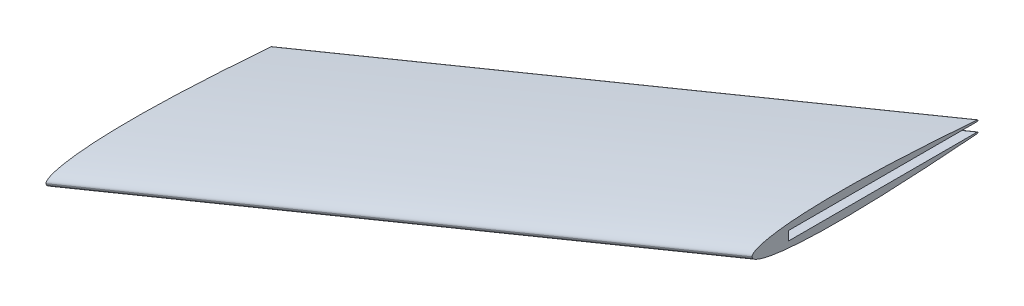
from build123d import *

# Parameters (mm, degrees)
SHAPE_OF_FINS_W                        = 146.05
SHAPE_OF_FINS_H                        = 76.2
CUT_FIN_SHAPE_BOTTOM_NO_MIDPLANE_DEPTH = 1.5875
SHAPE_OF_FINS_2_W                      = 146.05
SHAPE_OF_FINS_2_H                      = 76.2
CUT_FIN_SHAPE_TOP_NO_MIDPLANE_DEPTH    = 1.5875
FILLET1_R                              = 0.254


with BuildPart() as part:
    # Sketch2 → Loft1 section 0
    with BuildSketch(Plane(origin=(0, 0, 0), x_dir=(0, 0, -1), z_dir=(1, 0, 0))):
        with BuildLine():
            add(Edge.make_bspline(
                [(0, 0), (6.037e-05, 0.063965482), (0.008337384, 0.147065594), (0.033006292, 0.251891655), (0.08645397, 0.385600932), (0.14207511, 0.49175055), (0.2260735, 0.616551323), (0.352403438, 0.764641209), (0.538628729, 0.939487069), (0.828348412, 1.156294496), (1.308084735, 1.439447596), (2.168542592, 1.828433537), (3.779864919, 2.360255288), (6.811797919, 3.043241983), (11.632647218, 3.715252615), (18.029726602, 4.209542087), (25.596479128, 4.457376446), (33.615045989, 4.467520125), (41.631691137, 4.296624051), (48.642181709, 4.028955027), (54.648718032, 3.734026719), (59.651358251, 3.451214099), (63.653671912, 3.204562152), (67.652012966, 2.939591438), (71.65390429, 2.656662143), (76.645752217, 2.283143899), (81.650487029, 1.880997226), (86.627434, 1.454724014), (91.141337569, 1.041731795), (94.097674415, 0.760765672), (96.658493215, 0.50845313), (98.511307899, 0.322470736), (100.230673004, 0.14422955), (101.146764626, 0.048035868), (101.6, 0)],
                knots=[0, 0, 0, 0, 0, 0.002249104, 0.002957062, 0.003788844, 0.005088535, 0.006482081, 0.008270166, 0.010664697, 0.014111356, 0.019264938, 0.027949637, 0.044027879, 0.074069386, 0.129126931, 0.200071999, 0.271017071, 0.341962144, 0.412907218, 0.483852292, 0.519324829, 0.554797366, 0.590269903, 0.625742441, 0.661214978, 0.696687515, 0.767632588, 0.803105125, 0.838577662, 0.856313931, 0.8740502, 0.891786469, 0.909522737, 0.909522737, 0.909522737, 0.909522737, 0.909522737], degree=4))
            add(Edge.make_bspline(
                [(0, 0), (6.037e-05, -0.063965482), (0.008337384, -0.147065594), (0.033006292, -0.251891655), (0.08645397, -0.385600932), (0.14207511, -0.49175055), (0.2260735, -0.616551323), (0.352403438, -0.764641209), (0.538628729, -0.939487069), (0.828348412, -1.156294496), (1.308084735, -1.439447596), (2.168542592, -1.828433537), (3.779864919, -2.360255288), (6.811797919, -3.043241983), (11.632647218, -3.715252615), (18.029726602, -4.209542087), (25.596479128, -4.457376446), (33.615045989, -4.467520125), (41.631691137, -4.296624051), (48.642181709, -4.028955027), (54.648718032, -3.734026719), (59.651358251, -3.451214099), (63.653671912, -3.204562152), (67.652012966, -2.939591438), (71.65390429, -2.656662143), (76.645752217, -2.283143899), (81.650487029, -1.880997226), (86.627434, -1.454724014), (91.141337569, -1.041731795), (94.097674415, -0.760765672), (96.658493215, -0.50845313), (98.511307899, -0.322470736), (100.230673004, -0.14422955), (101.146764626, -0.048035868), (101.6, 0)],
                knots=[0, 0, 0, 0, 0, 0.002249104, 0.002957062, 0.003788844, 0.005088535, 0.006482081, 0.008270166, 0.010664697, 0.014111356, 0.019264938, 0.027949637, 0.044027879, 0.074069386, 0.129126931, 0.200071999, 0.271017071, 0.341962144, 0.412907218, 0.483852292, 0.519324829, 0.554797366, 0.590269903, 0.625742441, 0.661214978, 0.696687515, 0.767632588, 0.803105125, 0.838577662, 0.856313931, 0.8740502, 0.891786469, 0.909522737, 0.909522737, 0.909522737, 0.909522737, 0.909522737], degree=4))
        make_face()
    # Sketch3 → Loft1 section 1
    with BuildSketch(Plane(origin=(146.05, 0, 0), x_dir=(0, 0, -1), z_dir=(1, 0, 0))):
        with BuildLine():
            add(Edge.make_bspline(
                [(101.6, 0), (101.60006037, 0.063965482), (101.608337384, 0.147065594), (101.633006292, 0.251891655), (101.68645397, 0.385600932), (101.74207511, 0.49175055), (101.8260735, 0.616551323), (101.952403438, 0.764641209), (102.138628729, 0.939487069), (102.428348412, 1.156294496), (102.908084735, 1.439447596), (103.768542592, 1.828433537), (105.379864919, 2.360255288), (108.411797919, 3.043241983), (113.232647218, 3.715252615), (119.629726602, 4.209542087), (127.196479128, 4.457376446), (135.215045989, 4.467520125), (143.231691137, 4.296624051), (150.242181709, 4.028955027), (156.248718032, 3.734026719), (161.251358251, 3.451214099), (165.253671912, 3.204562152), (169.252012966, 2.939591438), (173.25390429, 2.656662143), (178.245752217, 2.283143899), (183.250487029, 1.880997226), (188.227434, 1.454724014), (192.741337569, 1.041731795), (195.697674415, 0.760765672), (198.258493215, 0.50845313), (200.111307899, 0.322470736), (201.830673004, 0.14422955), (202.746764626, 0.048035868), (203.2, 0)],
                knots=[0, 0, 0, 0, 0, 0.002249104, 0.002957062, 0.003788844, 0.005088535, 0.006482081, 0.008270166, 0.010664697, 0.014111356, 0.019264938, 0.027949637, 0.044027879, 0.074069386, 0.129126931, 0.200071999, 0.271017071, 0.341962144, 0.412907218, 0.483852292, 0.519324829, 0.554797366, 0.590269903, 0.625742441, 0.661214978, 0.696687515, 0.767632588, 0.803105125, 0.838577662, 0.856313931, 0.8740502, 0.891786469, 0.909522737, 0.909522737, 0.909522737, 0.909522737, 0.909522737], degree=4))
            add(Edge.make_bspline(
                [(101.6, 0), (101.60006037, -0.063965482), (101.608337384, -0.147065594), (101.633006292, -0.251891655), (101.68645397, -0.385600932), (101.74207511, -0.49175055), (101.8260735, -0.616551323), (101.952403438, -0.764641209), (102.138628729, -0.939487069), (102.428348412, -1.156294496), (102.908084735, -1.439447596), (103.768542592, -1.828433537), (105.379864919, -2.360255288), (108.411797919, -3.043241983), (113.232647218, -3.715252615), (119.629726602, -4.209542087), (127.196479128, -4.457376446), (135.215045989, -4.467520125), (143.231691137, -4.296624051), (150.242181709, -4.028955027), (156.248718032, -3.734026719), (161.251358251, -3.451214099), (165.253671912, -3.204562152), (169.252012966, -2.939591438), (173.25390429, -2.656662143), (178.245752217, -2.283143899), (183.250487029, -1.880997226), (188.227434, -1.454724014), (192.741337569, -1.041731795), (195.697674415, -0.760765672), (198.258493215, -0.50845313), (200.111307899, -0.322470736), (201.830673004, -0.14422955), (202.746764626, -0.048035868), (203.2, 0)],
                knots=[0, 0, 0, 0, 0, 0.002249104, 0.002957062, 0.003788844, 0.005088535, 0.006482081, 0.008270166, 0.010664697, 0.014111356, 0.019264938, 0.027949637, 0.044027879, 0.074069386, 0.129126931, 0.200071999, 0.271017071, 0.341962144, 0.412907218, 0.483852292, 0.519324829, 0.554797366, 0.590269903, 0.625742441, 0.661214978, 0.696687515, 0.767632588, 0.803105125, 0.838577662, 0.856313931, 0.8740502, 0.891786469, 0.909522737, 0.909522737, 0.909522737, 0.909522737, 0.909522737], degree=4))
        make_face()
    loft()

    # Shape Of Fins → Cut Fin Shape - Bottom _No Midplane (cut)
    with BuildSketch(Plane(origin=(0, 0, 0), x_dir=(1, 0, 0), z_dir=(0, 1, 0))):
        with Locations((73.025, 254)):
            Rectangle(SHAPE_OF_FINS_W, SHAPE_OF_FINS_H)
        Polygon((146.05, 215.9), (0, 215.9), (0, 12.7), (146.05, 114.3), align=None)
    extrude(amount=-CUT_FIN_SHAPE_BOTTOM_NO_MIDPLANE_DEPTH, mode=Mode.SUBTRACT)

    # Shape Of Fins_2 → Cut Fin Shape - Top _No Midplane (cut)
    with BuildSketch(Plane(origin=(0, 0, 0), x_dir=(1, 0, 0), z_dir=(0, 1, 0))):
        Polygon((146.05, 215.9), (0, 215.9), (0, 12.7), (146.05, 114.3), align=None)
        with Locations((73.025, 254)):
            Rectangle(SHAPE_OF_FINS_2_W, SHAPE_OF_FINS_2_H)
    extrude(amount=CUT_FIN_SHAPE_TOP_NO_MIDPLANE_DEPTH, mode=Mode.SUBTRACT)

    # Fillet1
    fillet1_edges = [part.edges().sort_by_distance(p)[0] for p in [
        (73.025, 1.5875, -135.834819341),
        (73.025, -1.5875, -135.834819341),
    ]]
    fillet(fillet1_edges, radius=FILLET1_R)


solid = part.part
